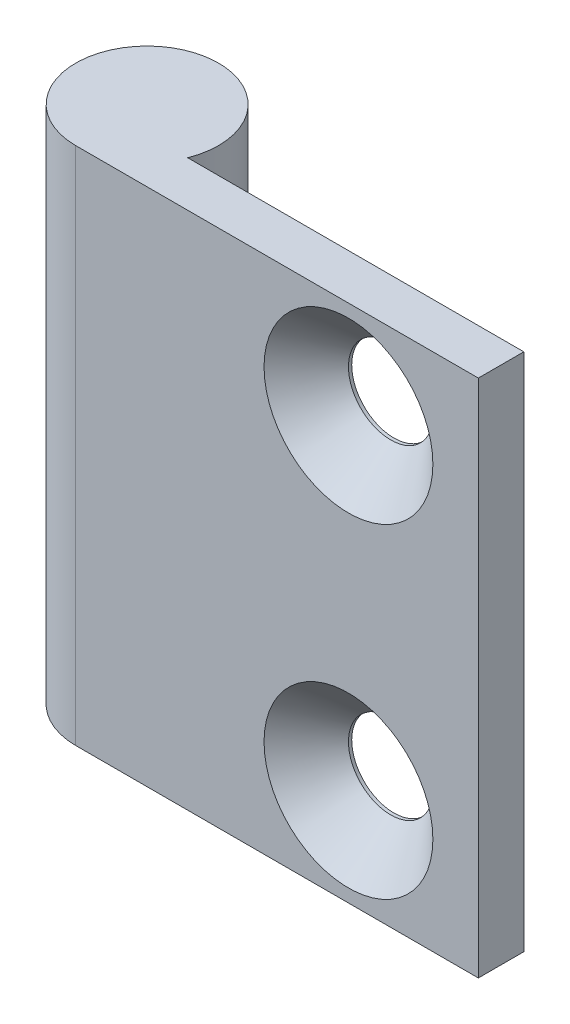
from build123d import *

# Parameters (mm, degrees)
EXTRUDE1_DEPTH       = 40
HOLEWZD1_D           = 6.5
HOLEWZD1_DEPTH       = 11
HOLEWZD1_CSINK_D     = 13
HOLEWZD1_CSINK_ANGLE = 90


with BuildPart() as part:
    # Sketch1 → Extrude1 (new body)
    with BuildSketch(Plane.XZ.offset(41.7)):
        with BuildLine():
            Line((31, 5.5), (0, 5.5))
            ThreePointArc((0, 5.5), (-3.102418411, -4.541475531), (5.123475383, 2))
            Line((5.123475383, 2), (31, 2))
            Line((31, 2), (31, 5.5))
        make_face()
    extrude(amount=-EXTRUDE1_DEPTH)

    # HoleWzd1
    with Locations(Plane.XY.offset(5.5)):
        with Locations((21, -34.2), (21, -9.2)):
            CounterSinkHole(HOLEWZD1_D / 2, HOLEWZD1_CSINK_D / 2, depth=HOLEWZD1_DEPTH, counter_sink_angle=HOLEWZD1_CSINK_ANGLE)


solid = part.part
